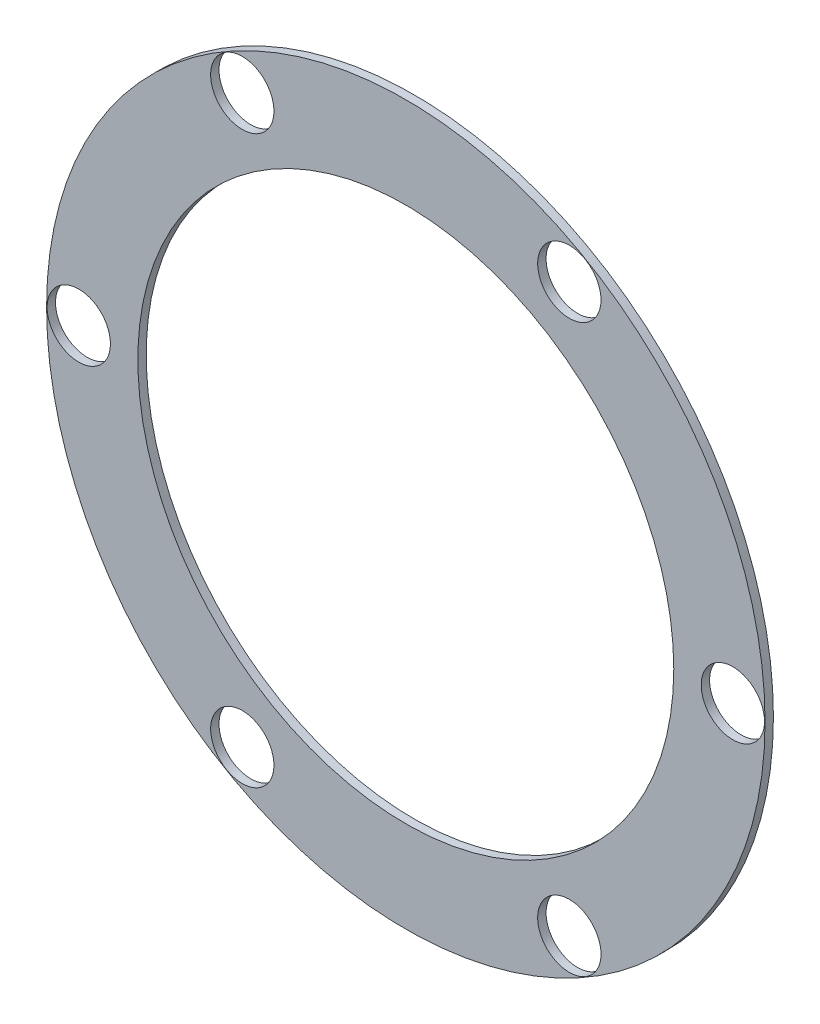
from build123d import *

# Parameters (mm, degrees)
SKETCH1_R           = 17.025679244
SKETCH1_R_2         = 1.5
SKETCH1_R_3         = 12.7
BOSS_EXTRUDE1_DEPTH = 0.396875


with BuildPart() as part:
    # Sketch1 → Boss-Extrude1 (new body)
    with BuildSketch(Plane.XY):
        Circle(SKETCH1_R)
        with Locations((-15.5, 0)):
            Circle(SKETCH1_R_2, mode=Mode.SUBTRACT)
        with Locations((-7.75, 13.423393759)):
            Circle(SKETCH1_R_2, mode=Mode.SUBTRACT)
        with Locations((7.75, 13.423393759)):
            Circle(SKETCH1_R_2, mode=Mode.SUBTRACT)
        with Locations((15.5, 0)):
            Circle(SKETCH1_R_2, mode=Mode.SUBTRACT)
        with Locations((7.75, -13.423393759)):
            Circle(SKETCH1_R_2, mode=Mode.SUBTRACT)
        with Locations((-7.75, -13.423393759)):
            Circle(SKETCH1_R_2, mode=Mode.SUBTRACT)
        Circle(SKETCH1_R_3, mode=Mode.SUBTRACT)
    extrude(amount=BOSS_EXTRUDE1_DEPTH)


solid = part.part
